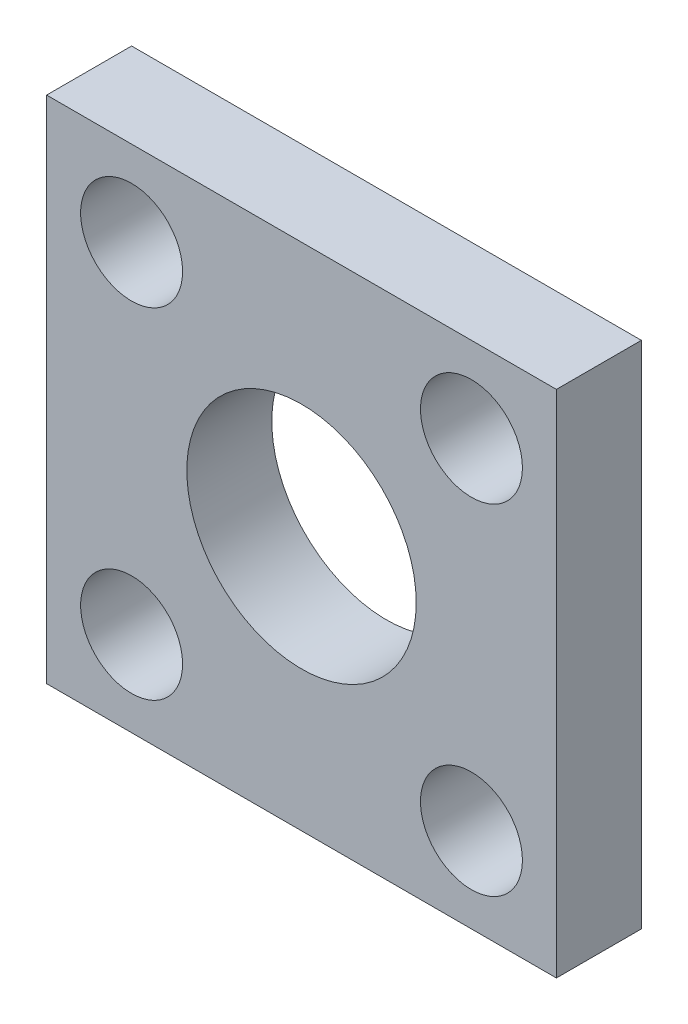
from build123d import *

# Parameters (mm, degrees)
IZIM1_W                     = 60
IZIM1_H                     = 60
IZIM1_R                     = 13.5
IZIM1_R_2                   = 6
Y_KSEKLIK_EKSTR_ZYON1_DEPTH = 10


with BuildPart() as part:
    # Çizim1 → Yükseklik-Ekstrüzyon1 (new body)
    with BuildSketch(Plane.XY):
        Rectangle(IZIM1_W, IZIM1_H)
        Circle(IZIM1_R, mode=Mode.SUBTRACT)
        with Locations((20, 20)):
            Circle(IZIM1_R_2, mode=Mode.SUBTRACT)
        with Locations((-20, 20)):
            Circle(IZIM1_R_2, mode=Mode.SUBTRACT)
        with Locations((20, -20)):
            Circle(IZIM1_R_2, mode=Mode.SUBTRACT)
        with Locations((-20, -20)):
            Circle(IZIM1_R_2, mode=Mode.SUBTRACT)
    extrude(amount=Y_KSEKLIK_EKSTR_ZYON1_DEPTH)


solid = part.part
